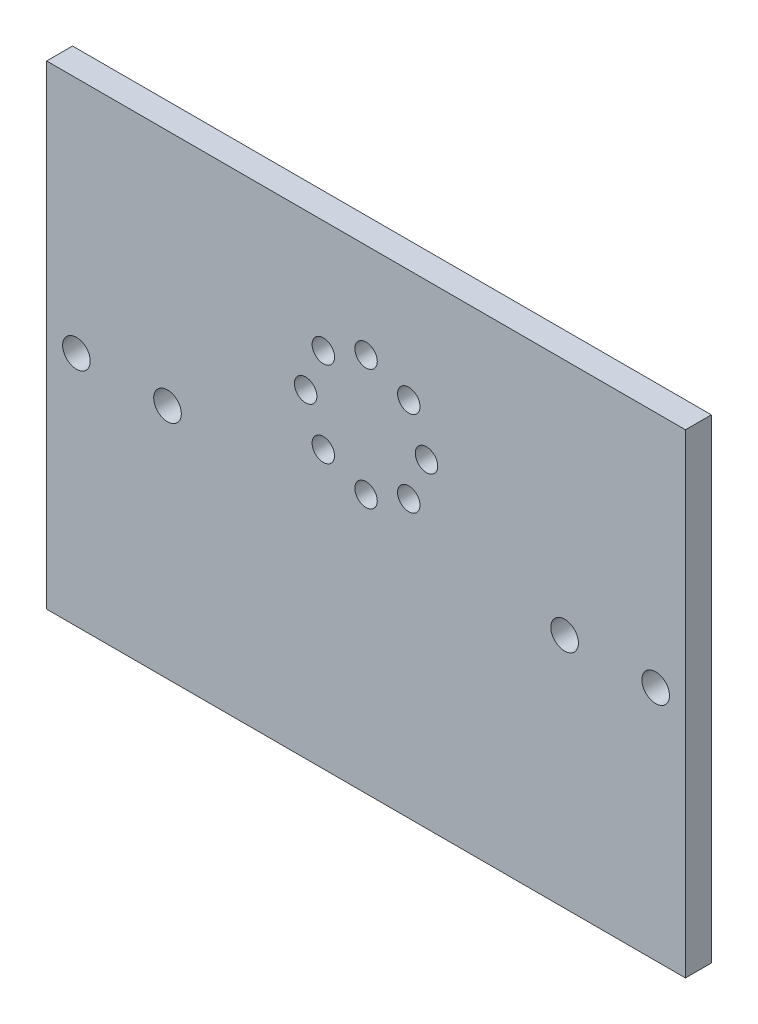
from build123d import *

# Parameters (mm, degrees)
SKETCH_1_W          = 74
SKETCH_1_H          = 55
EXTRUDE_1_DEPTH     = 3
SKETCH_2_R          = 1.6
CUT_EXTRUDE_1_DEPTH = 4
SKETCH_2_3_R        = 1.3
CUT_EXTRUDE_2_DEPTH = 4


with BuildPart() as part:
    # Sketch 1 → Extrude 1 (new body)
    with BuildSketch(Plane.XY):
        Rectangle(SKETCH_1_W, SKETCH_1_H)
    extrude(amount=EXTRUDE_1_DEPTH)

    # Sketch 2 → Cut-Extrude 1 (cut, through all)
    with BuildSketch(Plane.XY.offset(3)):
        with Locations((-33.55, -0.1)):
            Circle(SKETCH_2_R)
        with Locations((33.55, -0.1)):
            Circle(SKETCH_2_R)
        with Locations((-23, -0.1)):
            Circle(SKETCH_2_R)
        with Locations((23, -0.1)):
            Circle(SKETCH_2_R)
    extrude(amount=-CUT_EXTRUDE_1_DEPTH, mode=Mode.SUBTRACT)

    # Sketch 2_3 → Cut-Extrude 2 (cut, through all)
    with BuildSketch(Plane.XY.offset(3)):
        with Locations((0, 2.5)):
            Circle(SKETCH_2_3_R)
        with Locations((4.949747468, 4.550252532)):
            Circle(SKETCH_2_3_R)
        with Locations((7, 9.5)):
            Circle(SKETCH_2_3_R)
        with Locations((4.949747468, 14.449747468)):
            Circle(SKETCH_2_3_R)
        with Locations((-4.949747468, 14.449747468)):
            Circle(SKETCH_2_3_R)
        with Locations((-7, 9.5)):
            Circle(SKETCH_2_3_R)
        with Locations((-4.949747468, 4.550252532)):
            Circle(SKETCH_2_3_R)
        with Locations((0, 16.5)):
            Circle(SKETCH_2_3_R)
    extrude(amount=-CUT_EXTRUDE_2_DEPTH, mode=Mode.SUBTRACT)


solid = part.part
